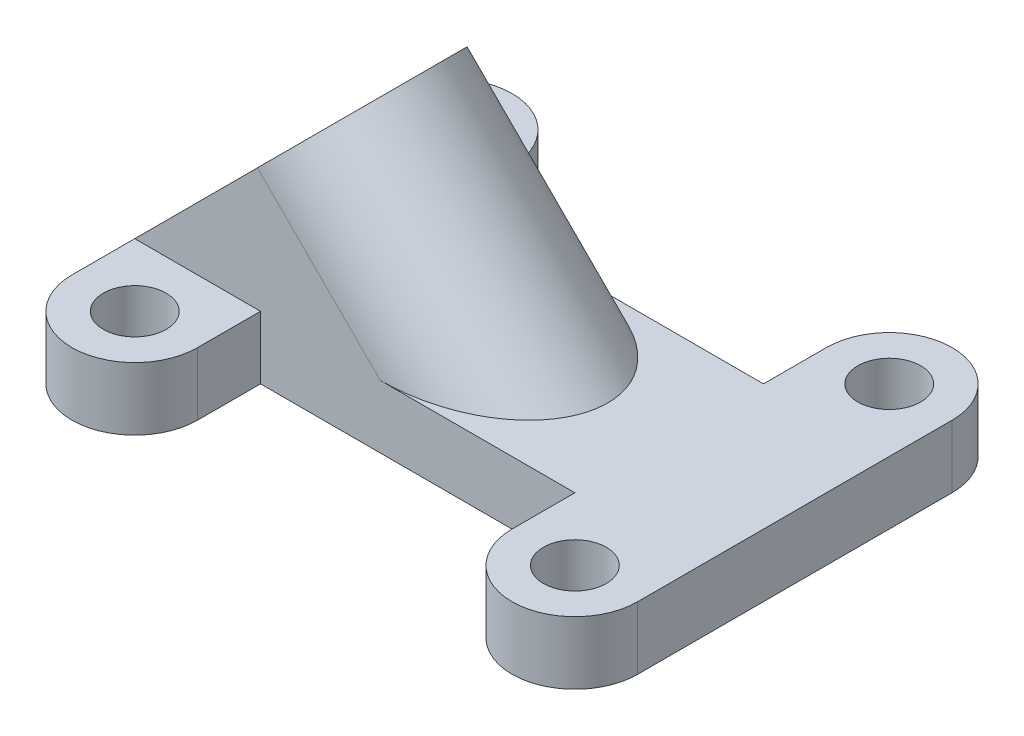
from build123d import *

# Parameters (mm, degrees)
SKETCH_1_R          = 2.5
EXTRUDE_1_DEPTH     = 5
EXTRUDE_3_REACH     = 37.355
SKETCH_6_R          = 3
SKETCH_9_R          = 3
CUT_EXTRUDE_2_DEPTH = 36.355339059


with BuildPart() as part:
    # 草圖1 → 填料-伸長1 (new body)
    with BuildSketch(Plane(origin=(0, 0, 0), x_dir=(1, 0, 0), z_dir=(0, 1, 0))):
        with BuildLine():
            Line((-12.5, 7.5), (12.5, 7.5))
            Line((12.5, 7.5), (12.5, 12.5))
            ThreePointArc((12.5, 12.5), (17.5, 17.5), (22.5, 12.5))
            Line((22.5, 12.5), (22.5, -12.5))
            ThreePointArc((22.5, -12.5), (17.5, -17.5), (12.5, -12.5))
            Line((12.5, -12.5), (12.5, -7.5))
            Line((12.5, -7.5), (-12.5, -7.5))
            Line((-12.5, -7.5), (-12.5, -12.5))
            ThreePointArc((-12.5, -12.5), (-17.5, -17.5), (-22.5, -12.5))
            Line((-22.5, -12.5), (-22.5, 12.5))
            ThreePointArc((-22.5, 12.5), (-17.5, 17.5), (-12.5, 12.5))
            Line((-12.5, 12.5), (-12.5, 7.5))
        make_face()
        with Locations((-17.5, -12.5)):
            Circle(SKETCH_1_R, mode=Mode.SUBTRACT)
        with Locations((-17.5, 12.5)):
            Circle(SKETCH_1_R, mode=Mode.SUBTRACT)
        with Locations((17.5, -12.5)):
            Circle(SKETCH_1_R, mode=Mode.SUBTRACT)
        with Locations((17.5, 12.5)):
            Circle(SKETCH_1_R, mode=Mode.SUBTRACT)
    extrude(amount=EXTRUDE_1_DEPTH)

    # 填料-伸長3: up to this face of the body (flat: up to its plane)
    extrude_3_end = Plane(part.part.faces().sort_by_distance((0, 0, 0))[0])
    # 草圖6 → 填料-伸長3 (add, up to the picked face)
    with BuildSketch(Plane(origin=(-13.75, 13.75, 0), x_dir=(0, 0, 1), z_dir=(-0.707106781, 0.707106781, 0)), mode=Mode.PRIVATE) as extrude_3_sk1:
        with BuildLine():
            Line((-7.5, -12.374368671), (-7.5, 1.425631329))
            ThreePointArc((-7.5, 1.425631329), (0, 8.925631329), (7.5, 1.425631329))
            Line((7.5, 1.425631329), (7.5, -12.374368671))
            Line((7.5, -12.374368671), (-7.5, -12.374368671))
        make_face()
        with Locations((0, 1.425631329)):
            Circle(SKETCH_6_R, mode=Mode.SUBTRACT)
    extrude_3_tool1 = split(extrude(extrude_3_sk1.sketch, amount=-EXTRUDE_3_REACH, mode=Mode.PRIVATE), bisect_by=extrude_3_end, keep=Keep.BOTH, mode=Mode.PRIVATE)
    add(extrude_3_tool1.solids().sort_by_distance((-15.778761, 11.721239, 0))[0])

    # 草圖9 → 除料-伸長2 (cut, through all)
    with BuildSketch(Plane(origin=(-13.75, 13.75, 0), x_dir=(0, 0, 1), z_dir=(-0.707106781, 0.707106781, 0))):
        with Locations((0, 1.425631329)):
            Circle(SKETCH_9_R)
    extrude(amount=-CUT_EXTRUDE_2_DEPTH, mode=Mode.SUBTRACT)


solid = part.part
